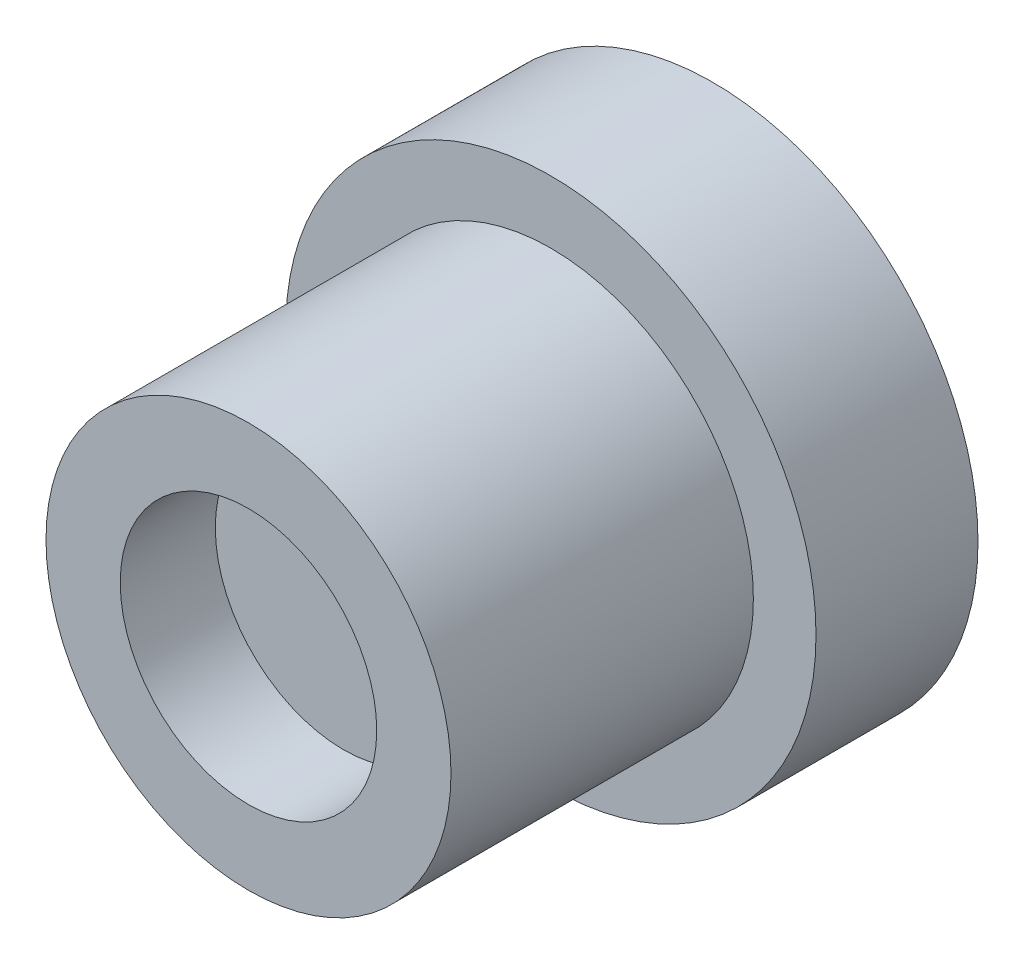
from build123d import *

# Parameters (mm, degrees)
SKETCH1_R           = 4.91
BOSS_EXTRUDE1_DEPTH = 3
SKETCH4_R           = 3.75
BOSS_EXTRUDE3_DEPTH = 3.84
SKETCH2_R           = 3.75
SKETCH2_R_2         = 2.375
BOSS_EXTRUDE2_DEPTH = 1.76


with BuildPart() as part:
    # Sketch1 → Boss-Extrude1 (new body)
    with BuildSketch(Plane.XY):
        Circle(SKETCH1_R)
    extrude(amount=BOSS_EXTRUDE1_DEPTH)

    # Sketch4 → Boss-Extrude3 (add)
    with BuildSketch(Plane.XY.offset(3)):
        Circle(SKETCH4_R)
    extrude(amount=BOSS_EXTRUDE3_DEPTH)

    # Sketch2 → Boss-Extrude2 (add)
    with BuildSketch(Plane.XY.offset(6.84)):
        Circle(SKETCH2_R)
        Circle(SKETCH2_R_2, mode=Mode.SUBTRACT)
    extrude(amount=BOSS_EXTRUDE2_DEPTH)


solid = part.part
